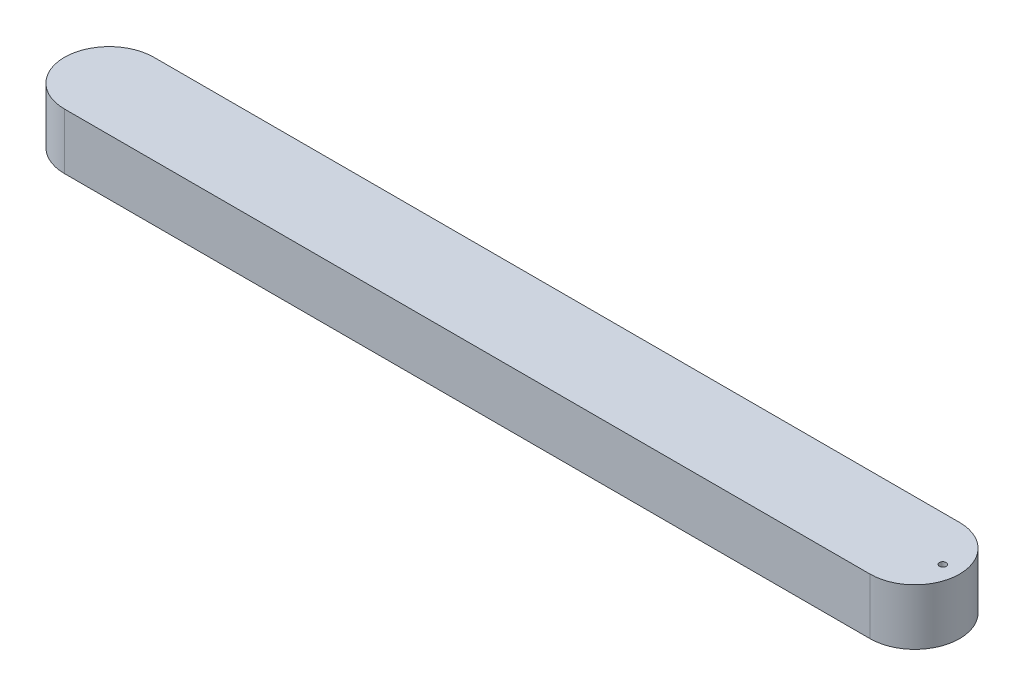
from build123d import *

# Parameters (mm, degrees)
BOSS_EXTRUDE1_DEPTH = 50
CUT_EXTRUDE2_DEPTH  = 4
CUT_EXTRUDE14_DEPTH = 6
CUT_EXTRUDE16_DEPTH = 30
HOLE1_D             = 6


with BuildPart() as part:
    # Sketch1 → Boss-Extrude1 (new body)
    with BuildSketch(Plane(origin=(0, 0, 0), x_dir=(1, 0, 0), z_dir=(0, 1, 0))):
        with BuildLine():
            Line((-360, 39.99999406), (360, 39.99999406))
            ThreePointArc((360, 39.99999406), (399.999998105, -4.045e-06), (360, -40))
            Line((360, -40), (-360, -40))
            ThreePointArc((-360, -40), (-399.99999406, -5.94e-06), (-360, 39.99999406))
        make_face()
    extrude(amount=BOSS_EXTRUDE1_DEPTH)

    # Sketch4 → Cut-Extrude2 (cut)
    with BuildSketch(Plane.XZ):
        with BuildLine():
            Line((360, 35.000001075), (-360, 35.000001485))
            ThreePointArc((-360, 35.000001485), (-394.999995545, 5.94e-06), (-360, -34.999989605))
            Line((-360, -34.999989605), (360.000000021, -34.99999406))
            ThreePointArc((360.000000021, -34.99999406), (394.999998105, 4.055e-06), (360, 35.000001075))
        make_face()
    extrude(amount=-CUT_EXTRUDE2_DEPTH, mode=Mode.SUBTRACT)

    # Sketch15 → Cut-Extrude14 (cut)
    with BuildSketch(Plane.XZ.offset(-4)):
        with BuildLine():
            Line((360, -30), (-360, -30))
            ThreePointArc((-360, -30), (-364, -26), (-360, -22))
            Line((-360, -22), (-360, 22))
            ThreePointArc((-360, 22), (-364, 26), (-360, 30))
            Line((-360, 30), (360, 30))
            ThreePointArc((360, 30), (364, 26), (360, 22))
            Line((360, 22), (360, -22))
            ThreePointArc((360, -22), (364, -26), (360, -30))
        make_face()
    extrude(amount=-CUT_EXTRUDE14_DEPTH, mode=Mode.SUBTRACT)

    # Sketch2 → Cut-Extrude16 (cut)
    with BuildSketch(Plane.XZ.offset(-4)):
        with BuildLine():
            Line((356, -26.99999406), (-356, -26.99999406))
            ThreePointArc((-356, -26.99999406), (-358.828427125, -25.828421185), (-360, -22.99999406))
            Line((-360, -22.99999406), (-360, 23))
            ThreePointArc((-360, 23), (-358.828427125, 25.828427125), (-356, 27))
            Line((-356, 27), (356, 27))
            ThreePointArc((356, 27), (358.828427125, 25.828427125), (360, 23))
            Line((360, 23), (360, -22.99999406))
            ThreePointArc((360, -22.99999406), (358.828427125, -25.828421185), (356, -26.99999406))
        make_face()
    extrude(amount=-CUT_EXTRUDE16_DEPTH, mode=Mode.SUBTRACT)

    # Hole1 (through all)
    with Locations(Plane(origin=(0, 4, 0), x_dir=(-1, 0, 0), z_dir=(0, -1, 0))):
        with Locations((-385, 0)):
            Hole(HOLE1_D / 2)


solid = part.part
